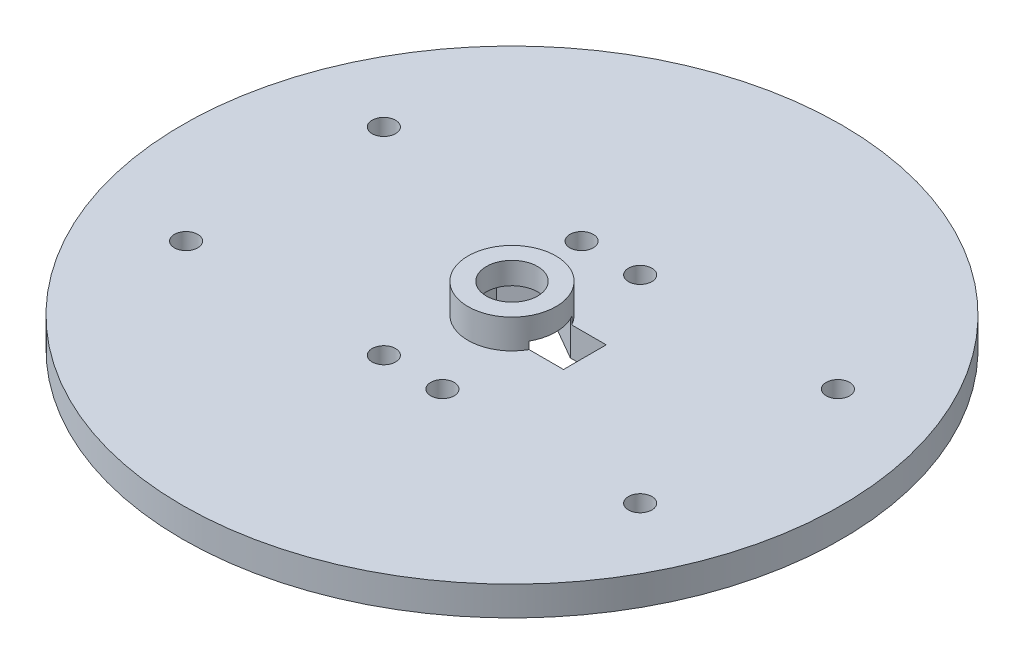
from build123d import *

# Parameters (mm, degrees)
SKETCH_1_R          = 45
EXTRUDE_1_DEPTH     = 4
SKETCH_13_R         = 6
EXTRUDE_5_DEPTH     = 4
SKETCH_15_R         = 1.6
CUT_EXTRUDE_5_DEPTH = 5
CUT_EXTRUDE_6_DEPTH = 5
SKETCH_20_R         = 3.5
CUT_EXTRUDE_7_DEPTH = 5
SKETCH_21_R         = 1.6
CUT_EXTRUDE_8_DEPTH = 5


with BuildPart() as part:
    # Эскиз1 → Бобышка-Вытянуть1 (new body)
    with BuildSketch(Plane(origin=(0, 0, 0), x_dir=(1, 0, 0), z_dir=(0, 1, 0))):
        Circle(SKETCH_1_R)
    extrude(amount=EXTRUDE_1_DEPTH)

    # Эскиз13 → Бобышка-Вытянуть5 (add)
    with BuildSketch(Plane(origin=(0, 4, 0), x_dir=(1, 0, 0), z_dir=(0, 1, 0))):
        Circle(SKETCH_13_R)
    extrude(amount=EXTRUDE_5_DEPTH)

    # Эскиз15 → Вырез-Вытянуть5 (cut, through all)
    with BuildSketch(Plane(origin=(0, 4, 0), x_dir=(1, 0, 0), z_dir=(0, 1, 0))):
        with Locations((-4, 13.5)):
            Circle(SKETCH_15_R)
        with Locations((-4, -13.5)):
            Circle(SKETCH_15_R)
        with Locations((4, -13.5)):
            Circle(SKETCH_15_R)
        with Locations((4, 13.5)):
            Circle(SKETCH_15_R)
    extrude(amount=-CUT_EXTRUDE_5_DEPTH, mode=Mode.SUBTRACT)

    # Эскиз19 → Вырез-Вытянуть6 (cut)
    with BuildSketch(Plane.XZ):
        Polygon((5.05, 2.915618859), (0, 5.831237719), (-5.05, 2.915618859), (-5.05, -2.915618859), (0, -5.831237719), (5.05, -2.915618859), (9.95, -2.915618859), (9.95, 2.915618859), align=None)
    extrude(amount=-CUT_EXTRUDE_6_DEPTH, mode=Mode.SUBTRACT)

    # Эскиз20 → Вырез-Вытянуть7 (cut)
    with BuildSketch(Plane.XZ.offset(-5)):
        Circle(SKETCH_20_R)
    extrude(amount=-CUT_EXTRUDE_7_DEPTH, mode=Mode.SUBTRACT)

    # Эскиз21 → Вырез-Вытянуть8 (cut)
    with BuildSketch(Plane.XZ):
        with Locations((4, 13.5)):
            Circle(SKETCH_21_R)
        with Locations((4, -13.5)):
            Circle(SKETCH_21_R)
        with Locations((31, 13.5)):
            Circle(SKETCH_21_R)
        with Locations((31, -13.5)):
            Circle(SKETCH_21_R)
        with Locations((-31, 13.5)):
            Circle(SKETCH_21_R)
        with Locations((-31, -13.5)):
            Circle(SKETCH_21_R)
    extrude(amount=-CUT_EXTRUDE_8_DEPTH, mode=Mode.SUBTRACT)


solid = part.part
